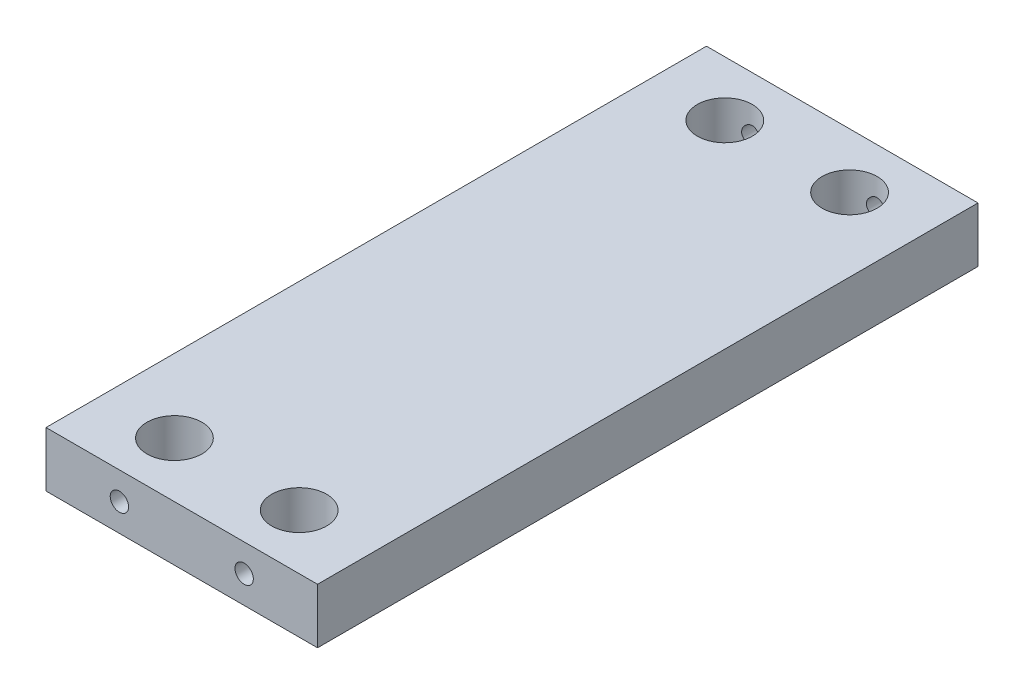
from build123d import *

# Parameters (mm, degrees)
SKETCH1_W           = 93.98
SKETCH1_H           = 228.6
BOSS_EXTRUDE1_DEPTH = 19.05


with BuildPart() as part:
    # Sketch1 → Boss-Extrude1 (new body)
    with BuildSketch(Plane(origin=(0, 0, 0), x_dir=(1, 0, 0), z_dir=(0, 1, 0))):
        Rectangle(SKETCH1_W, SKETCH1_H)
    extrude(amount=BOSS_EXTRUDE1_DEPTH)

    # Sketch2 → 3/4 (0.75) Diameter Hole1 (revolve, cut)
    with BuildSketch(Plane(origin=(-21.59, 19.05, -95.25), x_dir=(0, 0, 1), z_dir=(1, 0, 0))):
        Polygon((0, 0), (0, 24.773197396), (9.525, 19.05), (9.525, 0), align=None)
    f_3_4_0_75_diameter_hole1 = revolve(axis=Axis((-21.59, 25.4, -95.25), (0, -1, 0)), mode=Mode.SUBTRACT)

    # Mirror1: 3/4 (0.75) Diameter Hole1 across plane
    add(f_3_4_0_75_diameter_hole1.mirror(Plane.XY), mode=Mode.SUBTRACT)

    # Mirror4: 3/4 (0.75) Diameter Hole1 across plane
    add(f_3_4_0_75_diameter_hole1.mirror(Plane(origin=(0, 0, 0), x_dir=(0, 0, 1), z_dir=(1, 0, 0))), mode=Mode.SUBTRACT)

    # Mirror4 copy 1 sketch → Mirror4 copy 1 (revolve, cut)
    with BuildSketch(Plane(origin=(21.59, 19.05, 95.25), x_dir=(0, 0, -1), z_dir=(-1, 0, 0))):
        Polygon((0, 0), (0, 24.773197396), (9.525, 19.05), (9.525, 0), align=None)
    revolve(axis=Axis((21.59, 25.4, 95.25), (0, -1, 0)), mode=Mode.SUBTRACT)

    # Sketch4 → 1/4 (0.25) Diameter Hole1 (revolve, cut)
    with BuildSketch(Plane(origin=(21.59, 9.525, -114.3), x_dir=(0, 1, 0), z_dir=(1, 0, 0))):
        Polygon((0, 0), (0, 20.957732465), (3.175, 19.05), (3.175, 0), align=None)
    f_1_4_0_25_diameter_hole1 = revolve(axis=Axis((21.59, 9.525, -120.65), (0, 0, 1)), mode=Mode.SUBTRACT)

    # Mirror5: 1/4 (0.25) Diameter Hole1 across plane
    add(f_1_4_0_25_diameter_hole1.mirror(Plane.XY), mode=Mode.SUBTRACT)

    # Mirror10: 1/4 (0.25) Diameter Hole1 across plane
    add(f_1_4_0_25_diameter_hole1.mirror(Plane(origin=(0, 0, 0), x_dir=(0, 0, 1), z_dir=(1, 0, 0))), mode=Mode.SUBTRACT)

    # Mirror10 copy 1 sketch → Mirror10 copy 1 (revolve, cut)
    with BuildSketch(Plane(origin=(-21.59, 9.525, 114.3), x_dir=(0, 1, 0), z_dir=(-1, 0, 0))):
        Polygon((0, 0), (0, 20.957732465), (3.175, 19.05), (3.175, 0), align=None)
    revolve(axis=Axis((-21.59, 9.525, 120.65), (0, 0, -1)), mode=Mode.SUBTRACT)


solid = part.part
